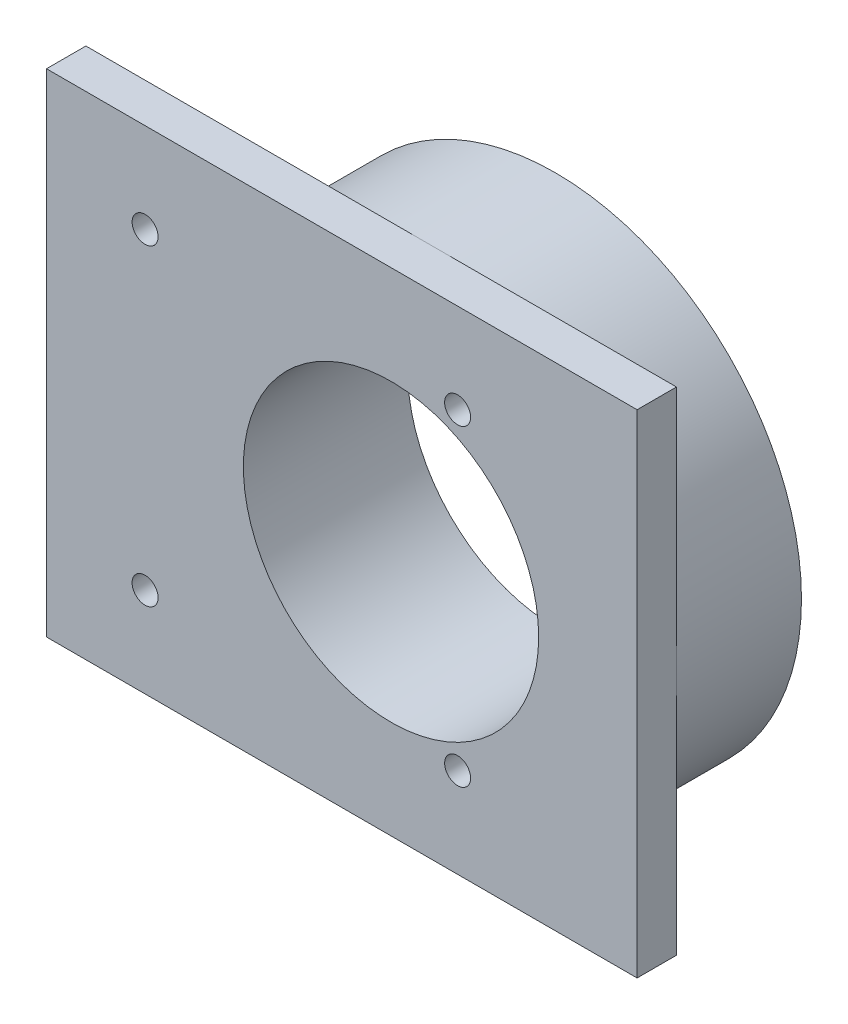
from build123d import *

# Parameters (mm, degrees)
SKETCH1_R           = 25
BOSS_EXTRUDE1_DEPTH = 12.7
SKETCH2_W           = 60
SKETCH2_H           = 50
BOSS_EXTRUDE2_DEPTH = 4
SKETCH3_R           = 1.32
CUT_EXTRUDE1_DEPTH  = 17.7
SKETCH4_R           = 15
CUT_EXTRUDE2_DEPTH  = 17.7


with BuildPart() as part:
    # Sketch1 → Boss-Extrude1 (new body)
    with BuildSketch(Plane.XY):
        Circle(SKETCH1_R)
    extrude(amount=BOSS_EXTRUDE1_DEPTH)

    # Sketch2 → Boss-Extrude2 (add)
    with BuildSketch(Plane.XY.offset(12.7)):
        with Locations((-5, 0)):
            Rectangle(SKETCH2_W, SKETCH2_H)
    extrude(amount=BOSS_EXTRUDE2_DEPTH)

    # Sketch3 → Cut-Extrude1 (cut, through all)
    with BuildSketch(Plane.XY.offset(16.7)):
        with Locations((-24.985, 15.875)):
            Circle(SKETCH3_R)
        with Locations((6.765, 15.875)):
            Circle(SKETCH3_R)
        with Locations((6.765, -15.875)):
            Circle(SKETCH3_R)
        with Locations((-24.985, -15.875)):
            Circle(SKETCH3_R)
    extrude(amount=-CUT_EXTRUDE1_DEPTH, mode=Mode.SUBTRACT)

    # Sketch4 → Cut-Extrude2 (cut, through all)
    with BuildSketch(Plane.XY.offset(16.7)):
        Circle(SKETCH4_R)
    extrude(amount=-CUT_EXTRUDE2_DEPTH, mode=Mode.SUBTRACT)


solid = part.part
